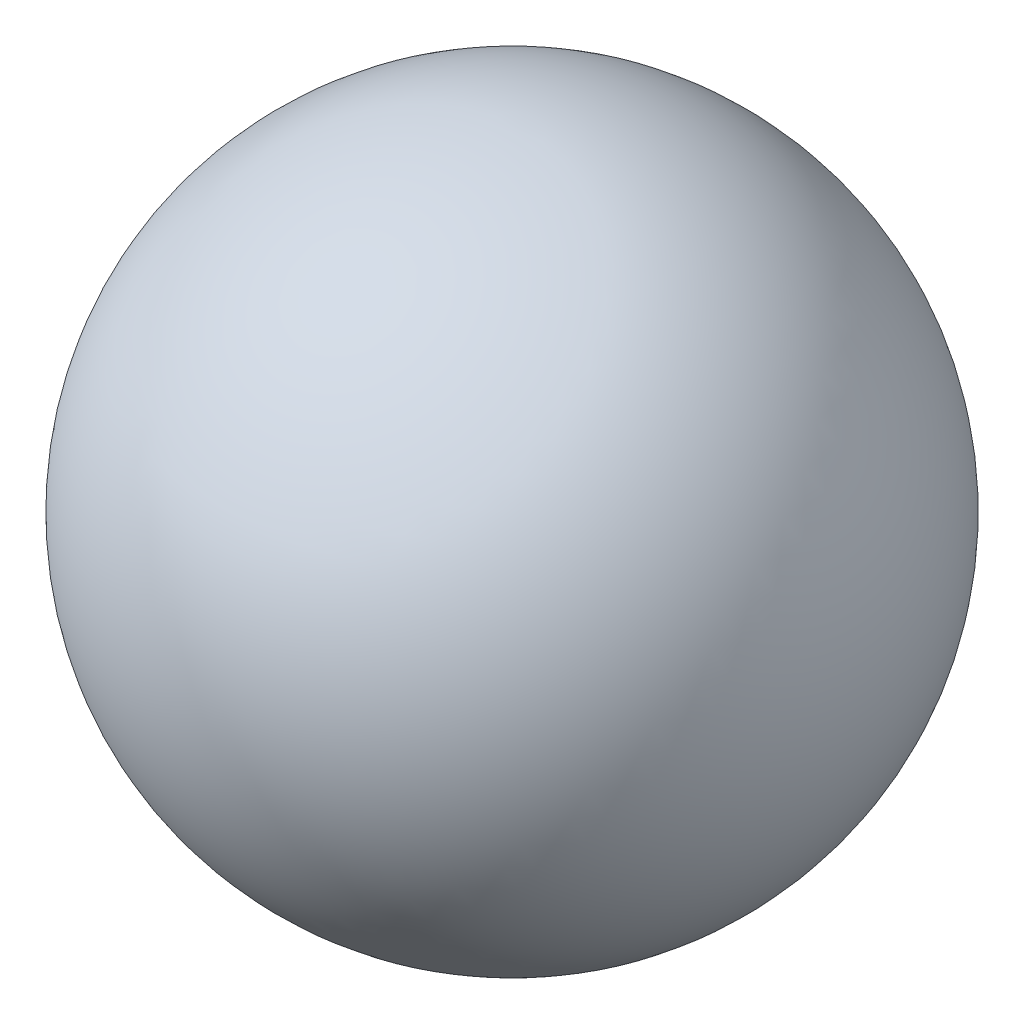
from build123d import *


with BuildPart() as part:
    # Sketch2 → Revolve1 (revolve)
    with BuildSketch(Plane(origin=(0, 0, 0), x_dir=(0, 0, -1), z_dir=(1, 0, 0))):
        with BuildLine():
            Line((0, -7), (0, 7))
            ThreePointArc((0, 7), (-7, 0), (0, -7))
        make_face()
    revolve(axis=Axis((0, -7, 0), (0, 1, 0)))


solid = part.part
